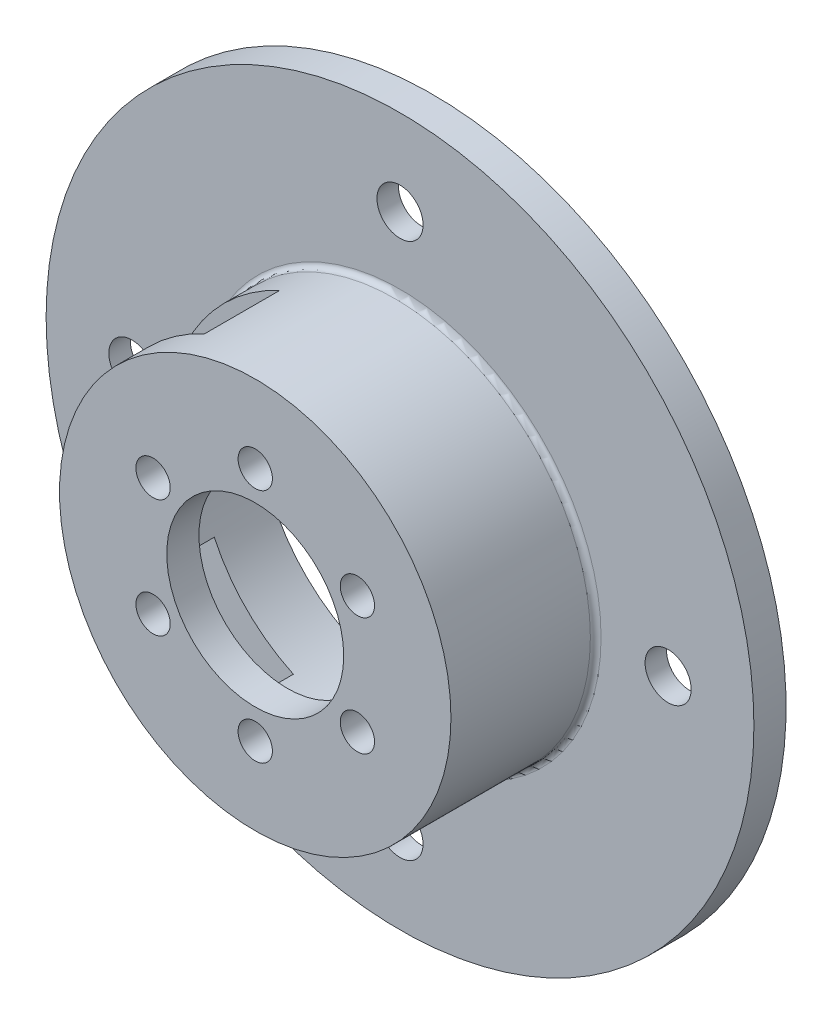
from build123d import *

# Parameters (mm, degrees)
SKETCH1_R            = 33
SKETCH1_R_2          = 15.25
BOSS_EXTRUDE1_DEPTH  = 4
SKETCH2_R            = 18.25
SKETCH2_R_2          = 15.25
BOSS_EXTRUDE2_DEPTH  = 13.5
SKETCH3_R            = 18.25
SKETCH3_R_2          = 8.25
BOSS_EXTRUDE3_DEPTH  = 3
M3_CLEARANCE_HOLE2_D = 3.2
CUT_EXTRUDE2_DEPTH   = 7
SKETCH10_R           = 35
CUT_EXTRUDE3_DEPTH   = 1
M4_CLEARANCE_HOLE1_D = 4.3
FILLET1_R            = 0.5
FILLET2_R            = 0.5
SKETCH13_R           = 30
CUT_EXTRUDE4_DEPTH   = 1
FILLET3_R            = 0.5


with BuildPart() as part:
    # Sketch1 → Boss-Extrude1 (new body)
    with BuildSketch(Plane.XY):
        Circle(SKETCH1_R)
        Circle(SKETCH1_R_2, mode=Mode.SUBTRACT)
    extrude(amount=BOSS_EXTRUDE1_DEPTH)

    # Sketch2 → Boss-Extrude2 (add)
    with BuildSketch(Plane.XY.offset(4)):
        Circle(SKETCH2_R)
        Circle(SKETCH2_R_2, mode=Mode.SUBTRACT)
    extrude(amount=BOSS_EXTRUDE2_DEPTH)

    # Sketch3 → Boss-Extrude3 (add)
    with BuildSketch(Plane.XY.offset(17.5)):
        Circle(SKETCH3_R)
        Circle(SKETCH3_R_2, mode=Mode.SUBTRACT)
    extrude(amount=-BOSS_EXTRUDE3_DEPTH)

    # M3 Clearance Hole2 (through all)
    with Locations(Plane.XY.offset(17.5)):
        with Locations((0, 11), (9.526279442, 5.5), (9.526279442, -5.5), (0, -11), (-9.526279442, -5.5), (-9.526279442, 5.5), (0, 0)):
            Hole(M3_CLEARANCE_HOLE2_D / 2)

    # Sketch9 → Cut-Extrude2 (cut)
    with BuildSketch(Plane.XY.offset(14.5)):
        with BuildLine():
            ThreePointArc((-12.688309019, 5.916655664), (-9.899494937, 9.899494937), (-5.916655664, 12.688309019))
            Line((-5.916655664, 12.688309019), (-7.712783277, 16.540117113))
            ThreePointArc((-7.712783277, 16.540117113), (-12.904698757, 12.904698757), (-16.540117113, 7.712783277))
            Line((-16.540117113, 7.712783277), (-12.688309019, 5.916655664))
        make_face()
        with BuildLine():
            Line((-7.712783277, -16.540117113), (-5.916655664, -12.688309019))
            ThreePointArc((-5.916655664, -12.688309019), (-9.899494937, -9.899494937), (-12.688309019, -5.916655664))
            Line((-12.688309019, -5.916655664), (-16.540117113, -7.712783277))
            ThreePointArc((-16.540117113, -7.712783277), (-12.904698757, -12.904698757), (-7.712783277, -16.540117113))
        make_face()
    extrude(amount=-CUT_EXTRUDE2_DEPTH, mode=Mode.SUBTRACT)

    # Sketch10 → Cut-Extrude3 (cut)
    with BuildSketch(Plane(origin=(0, 0, 0), x_dir=(-1, 0, 0), z_dir=(0, 0, -1))):
        Circle(SKETCH10_R)
    extrude(amount=-CUT_EXTRUDE3_DEPTH, mode=Mode.SUBTRACT)

    # M4 Clearance Hole1 (through all)
    with Locations(Plane.XY.offset(4)):
        with Locations((0, 25), (25, 0), (0, -25), (-25, 0), (0, 0)):
            Hole(M4_CLEARANCE_HOLE1_D / 2)

    # Fillet1
    fillet1_edges = [part.edges().sort_by_distance(p)[0] for p in [
        (-18.25, 0, 4),
        (-15.25, 0, 14.5),
    ]]
    fillet(fillet1_edges, radius=FILLET1_R)

    # Fillet2
    fillet2_edges = [part.edges().sort_by_distance(p)[0] for p in [
        (-15.25, 0, 1),
    ]]
    fillet(fillet2_edges, radius=FILLET2_R)

    # Sketch13 → Cut-Extrude4 (cut)
    with BuildSketch(Plane(origin=(0, 0, 1), x_dir=(-1, 0, 0), z_dir=(0, 0, -1))):
        Circle(SKETCH13_R)
    extrude(amount=-CUT_EXTRUDE4_DEPTH, mode=Mode.SUBTRACT)

    # Fillet3
    fillet3_edges = [part.edges().sort_by_distance(p)[0] for p in [
        (30, 0, 2),
    ]]
    fillet(fillet3_edges, radius=FILLET3_R)


solid = part.part
